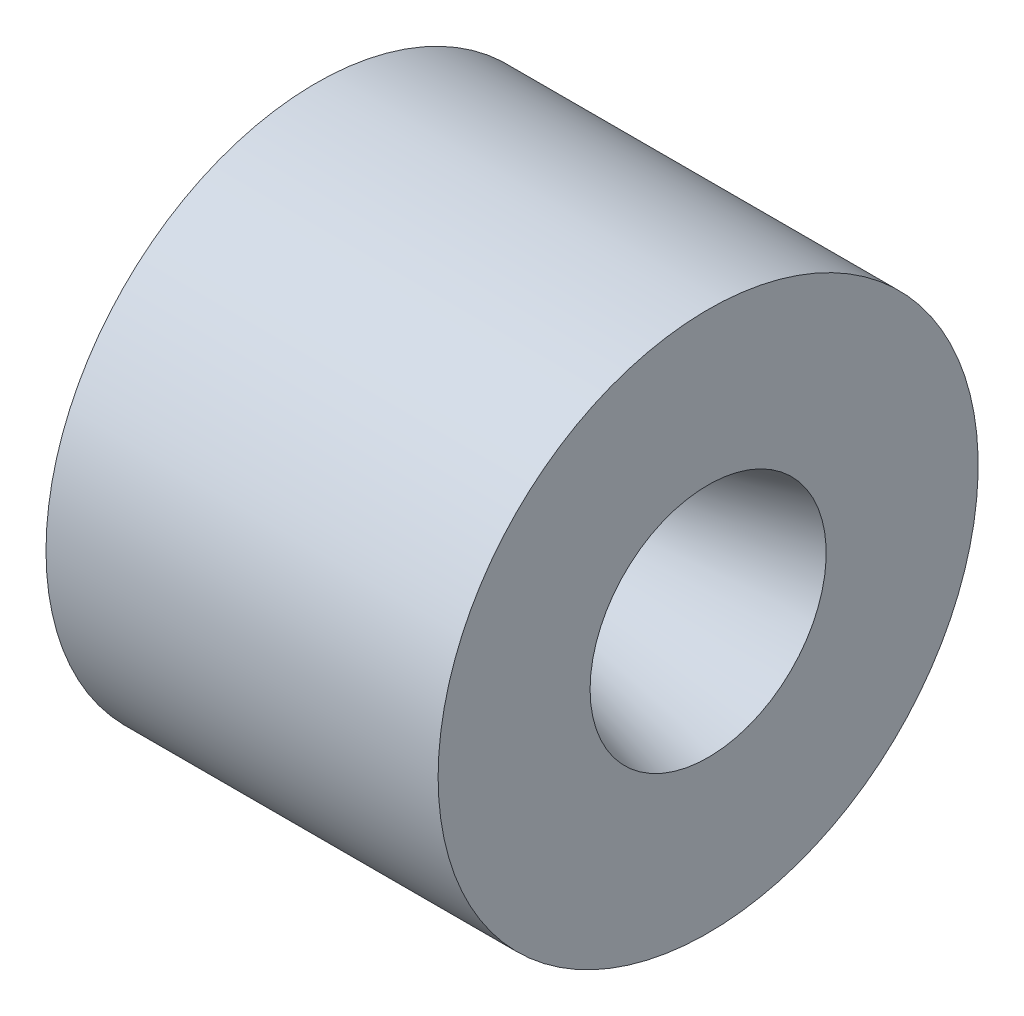
from build123d import *

# Parameters (mm, degrees)
SKETCH2_R          = 22.2885
SKETCH2_R_2        = 19.6723
CUT_EXTRUDE1_DEPTH = 2.286


with BuildPart() as part:
    # Sketch1 → Revolve1 (revolve)
    with BuildSketch(Plane.XY):
        Polygon((0, 24.13), (3.175, 24.13), (3.175, 15.875), (12.7, 6.35), (18.796, 6.35), (39.650699913, 11.938), (39.650699913, 27.305), (0, 27.305), align=None)
    revolve(axis=Axis((0, 0, 0), (1, 0, 0)))

    # Sketch2 → Cut-Extrude1 (cut)
    with BuildSketch(Plane.ZY.offset(-3.175)):
        Circle(SKETCH2_R)
        Circle(SKETCH2_R_2, mode=Mode.SUBTRACT)
    extrude(amount=-CUT_EXTRUDE1_DEPTH, mode=Mode.SUBTRACT)


solid = part.part
